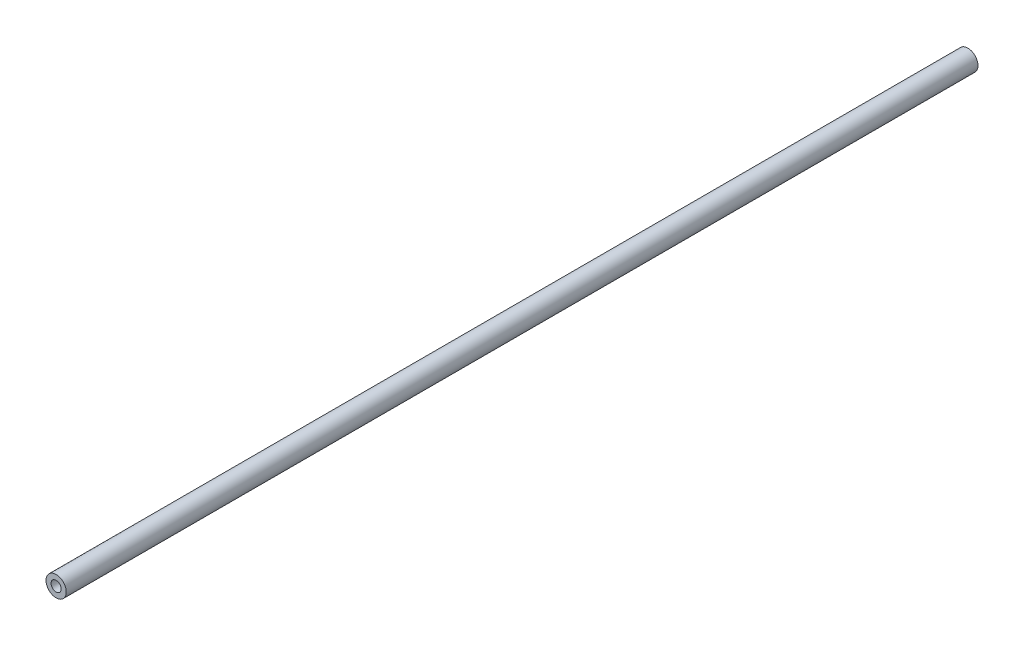
from build123d import *

# Parameters (mm, degrees)
SKETCH_1_R      = 2
SKETCH_1_R_2    = 1
EXTRUDE_1_DEPTH = 180


with BuildPart() as part:
    # 草图1 → 凸台-拉伸1 (new body)
    with BuildSketch(Plane.XY):
        Circle(SKETCH_1_R)
        Circle(SKETCH_1_R_2, mode=Mode.SUBTRACT)
    extrude(amount=EXTRUDE_1_DEPTH)


solid = part.part
